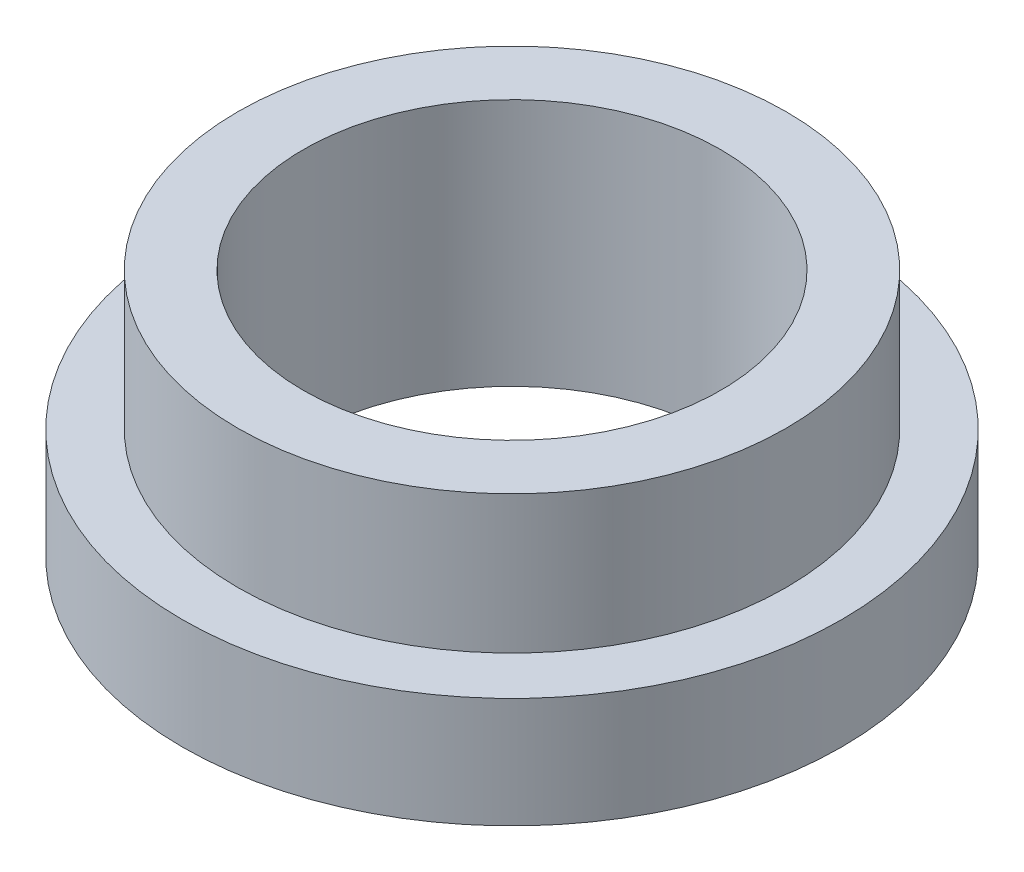
from build123d import *


with BuildPart() as part:
    # Sketch1 → Revolve1 (revolve)
    with BuildSketch(Plane.XY):
        Polygon((-3.025, 0), (-3.025, 3.6), (-3.975, 3.6), (-3.975, 1.6), (-4.78, 1.6), (-4.78, 0), align=None)
    revolve(axis=Axis((0, 0, 0), (0, 1, 0)))


solid = part.part
